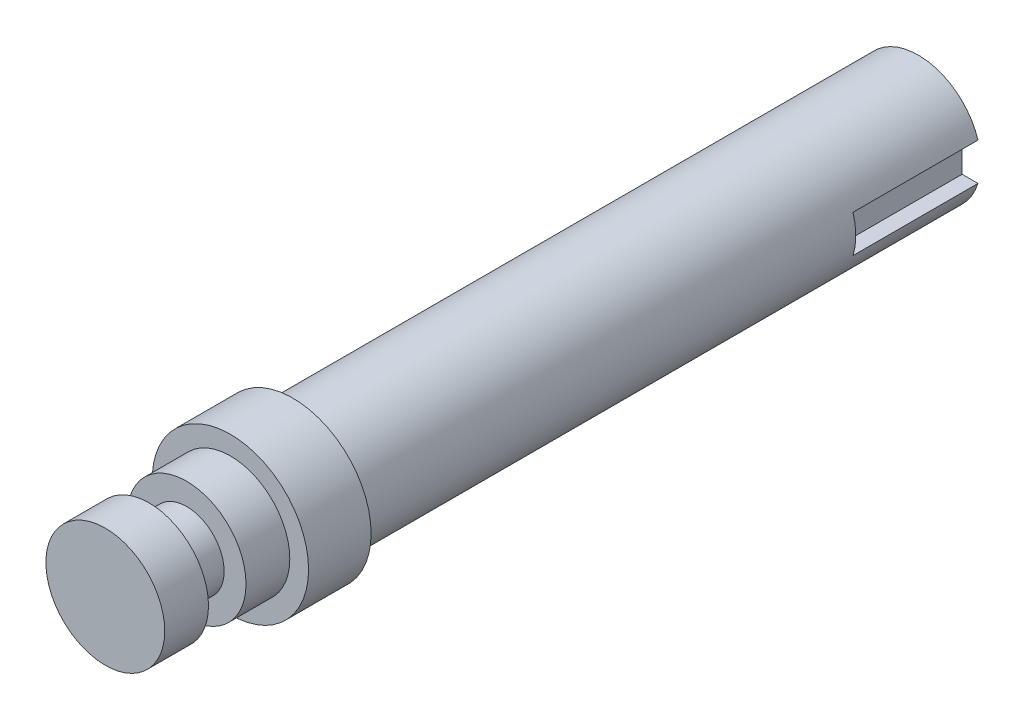
from build123d import *

# Parameters (mm, degrees)
SKETCH1_R           = 10
BOSS_EXTRUDE1_DEPTH = 100
SKETCH2_R           = 12.5
BOSS_EXTRUDE2_DEPTH = 10
SKETCH3_R           = 9.5
BOSS_EXTRUDE3_DEPTH = 7
SKETCH4_R           = 6
BOSS_EXTRUDE4_DEPTH = 6
SKETCH5_R           = 9.5
BOSS_EXTRUDE5_DEPTH = 7
SKETCH6_W           = 5
SKETCH6_H           = 6
CUT_EXTRUDE1_DEPTH  = 20


with BuildPart() as part:
    # Sketch1 → Boss-Extrude1 (new body)
    with BuildSketch(Plane.XY):
        Circle(SKETCH1_R)
    extrude(amount=BOSS_EXTRUDE1_DEPTH)

    # Sketch2 → Boss-Extrude2 (add)
    with BuildSketch(Plane.XY.offset(100)):
        Circle(SKETCH2_R)
    extrude(amount=BOSS_EXTRUDE2_DEPTH)

    # Sketch3 → Boss-Extrude3 (add)
    with BuildSketch(Plane.XY.offset(110)):
        Circle(SKETCH3_R)
    extrude(amount=BOSS_EXTRUDE3_DEPTH)

    # Sketch4 → Boss-Extrude4 (add)
    with BuildSketch(Plane.XY.offset(117)):
        Circle(SKETCH4_R)
    extrude(amount=BOSS_EXTRUDE4_DEPTH)

    # Sketch5 → Boss-Extrude5 (add)
    with BuildSketch(Plane.XY.offset(123)):
        Circle(SKETCH5_R)
    extrude(amount=BOSS_EXTRUDE5_DEPTH)

    # Sketch6 → Cut-Extrude1 (cut)
    with BuildSketch(Plane(origin=(0, 0, 0), x_dir=(-1, 0, 0), z_dir=(0, 0, -1))):
        with Locations((-9.5, 0)):
            Rectangle(SKETCH6_W, SKETCH6_H)
    extrude(amount=-CUT_EXTRUDE1_DEPTH, mode=Mode.SUBTRACT)


solid = part.part
